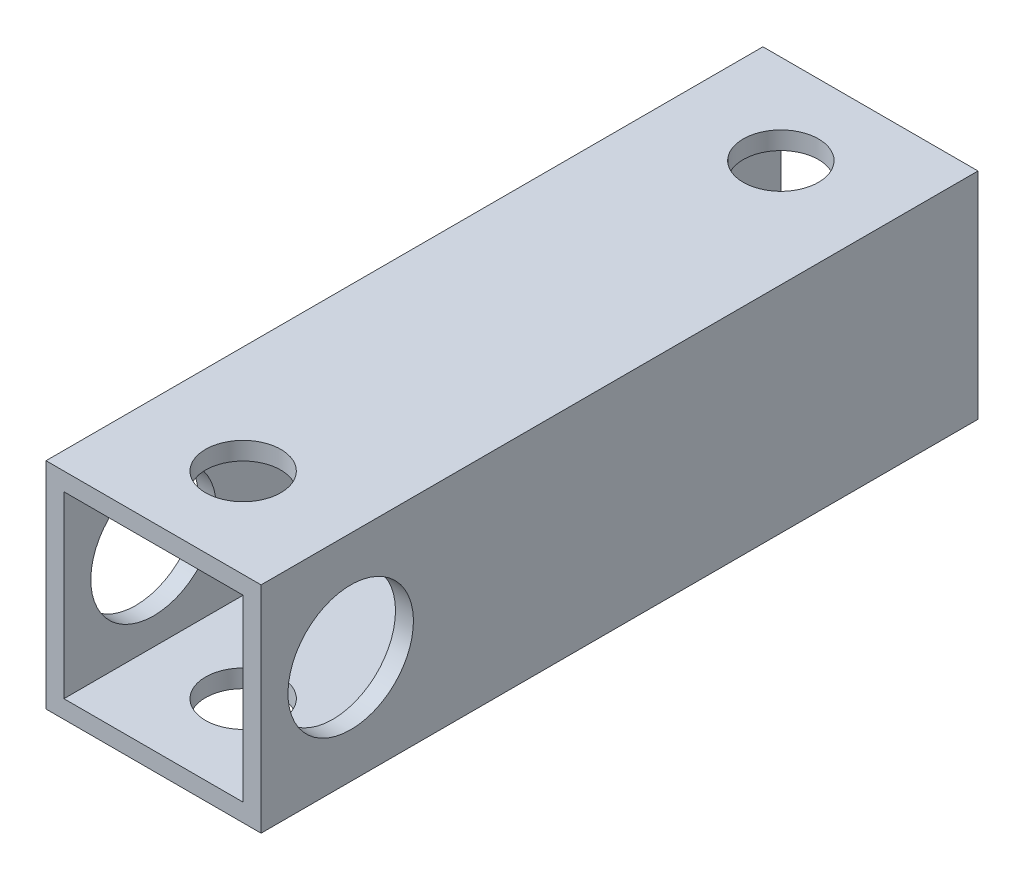
from build123d import *

# Parameters (mm, degrees)
SKETCH_1_W          = 12
SKETCH_1_H          = 12
EXTRUDE_1_DEPTH     = 40
SKETCH_2_W          = 10
SKETCH_2_H          = 10
CUT_EXTRUDE_1_DEPTH = 47.5
SKETCH_3_R          = 2.1
CUT_EXTRUDE_2_DEPTH = 47.5
SKETCH_5_R          = 3.5
CUT_EXTRUDE_4_DEPTH = 47.5


with BuildPart() as part:
    # ｽｹｯﾁ1 → ﾎﾞｽ - 押し出し1 (new body)
    with BuildSketch(Plane.XY):
        Rectangle(SKETCH_1_W, SKETCH_1_H)
    extrude(amount=EXTRUDE_1_DEPTH)

    # ｽｹｯﾁ2 → ｶｯﾄ - 押し出し1 (cut)
    with BuildSketch(Plane.XY.offset(40)):
        Rectangle(SKETCH_2_W, SKETCH_2_H)
    extrude(amount=-CUT_EXTRUDE_1_DEPTH, mode=Mode.SUBTRACT)

    # ｽｹｯﾁ3 → ｶｯﾄ - 押し出し2 (cut)
    with BuildSketch(Plane(origin=(0, 6, 0), x_dir=(1, 0, 0), z_dir=(0, 1, 0))):
        with Locations((0, -5)):
            Circle(SKETCH_3_R)
        with Locations((0, -35)):
            Circle(SKETCH_3_R)
    extrude(amount=-CUT_EXTRUDE_2_DEPTH, mode=Mode.SUBTRACT)

    # ｽｹｯﾁ5 → ｶｯﾄ - 押し出し4 (cut)
    with BuildSketch(Plane.ZY.offset(6)):
        with Locations((35, 0)):
            Circle(SKETCH_5_R)
    extrude(amount=-CUT_EXTRUDE_4_DEPTH, mode=Mode.SUBTRACT)


solid = part.part
